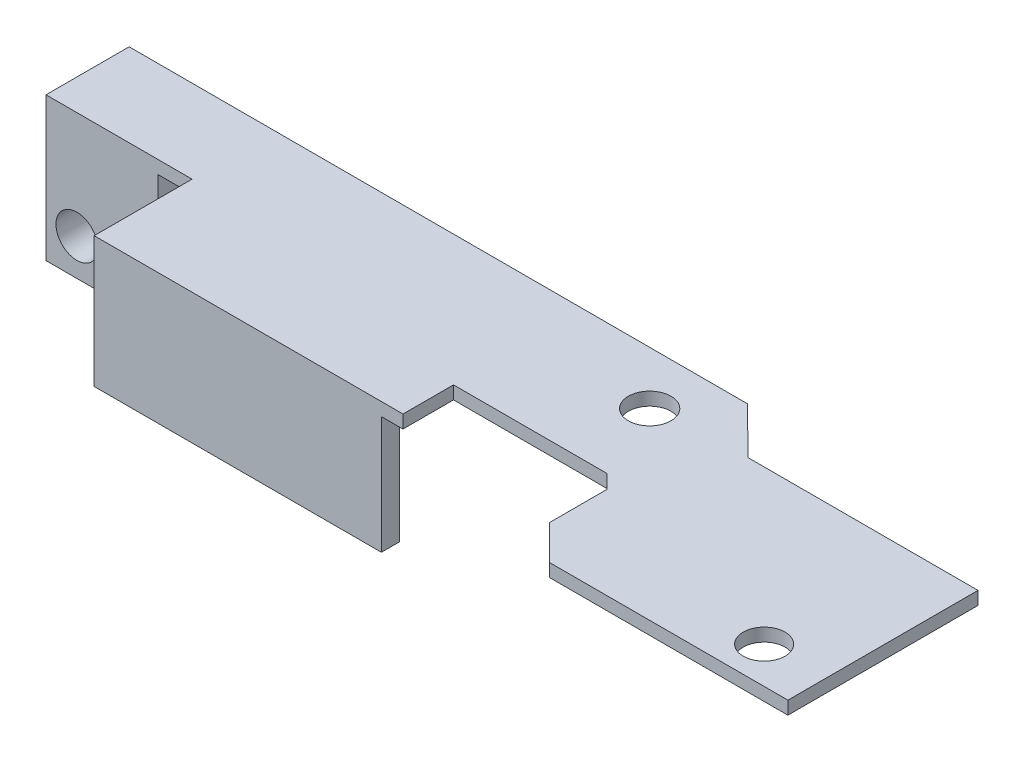
from build123d import *

# Parameters (mm, degrees)
SKETCH_1_R          = 1.632566579
SKETCH_1_R_2        = 1.6
EXTRUDE_1_DEPTH     = 1
SKETCH_2_W          = 21.996438878
SKETCH_2_H          = 1.4
EXTRUDE_2_DEPTH     = 9
SKETCH_3_W          = 9.861847607
SKETCH_3_H          = 7.366382786
EXTRUDE_3_DEPTH     = 10
CUT_EXTRUDE_1_REACH = 9.366
SKETCH_5_R          = 1.6
CUT_EXTRUDE_2_REACH = 13


with BuildPart() as part:
    # 草图1 → 凸台-拉伸1 (new body)
    with BuildSketch(Plane(origin=(0, 0, 0), x_dir=(1, 0, 0), z_dir=(0, 1, 0))):
        Polygon((-59.259088641, 5), (-10.592885375, 5), (-7.033226841, 1.452276921), (10.592885375, 1.452276921), (10.592885375, -5), (10.592885375, -13.105286597), (-7.648958362, -13.105286597), (-10.311746214, -10.442498745), (-10.311746214, -6.049690331), (-11.364057651, -4.997378894), (-11.364090146, -5), (-23.120004307, -5), (-23.120004307, -8.866382786), (-46.772006656, -8.866382786), (-46.772006656, -2.366382786), (-59.259088641, -2.366382786), (-59.259088641, 0), align=None)
        with Locations((-14.039400366, 0.94270398)):
            Circle(SKETCH_1_R, mode=Mode.SUBTRACT)
        with Locations((5.968790226, -10.300345076)):
            Circle(SKETCH_1_R_2, mode=Mode.SUBTRACT)
    extrude(amount=EXTRUDE_1_DEPTH)

    # 草图2 → 凸台-拉伸2 (add)
    with BuildSketch(Plane.XZ):
        with Locations((-35.773787217, 8.166382786)):
            Rectangle(SKETCH_2_W, SKETCH_2_H)
    extrude(amount=EXTRUDE_2_DEPTH)

    # 草图3 → 凸台-拉伸3 (add)
    with BuildSketch(Plane.XZ):
        with Locations((-54.328164838, -1.316808607)):
            Rectangle(SKETCH_3_W, SKETCH_3_H)
    extrude(amount=EXTRUDE_3_DEPTH)

    # 草图5 → 切除-拉伸1 (cut, up to next)
    with BuildSketch(Plane.XY.offset(2.366382786), mode=Mode.PRIVATE) as cut_extrude_1_sk1:
        with Locations((-55.594883285, -7.2)):
            Circle(SKETCH_5_R)
    cut_extrude_1_tool1 = extrude(cut_extrude_1_sk1.sketch, amount=-CUT_EXTRUDE_1_REACH, mode=Mode.PRIVATE) & part.part
    add(cut_extrude_1_tool1.solids().sort_by_distance((-55.594883, -7.2, 2.366383))[0], mode=Mode.SUBTRACT)

    # 草图6 → 切除-拉伸2 (cut, up to next)
    with BuildSketch(Plane(origin=(0, 1, 0), x_dir=(1, 0, 0), z_dir=(0, 1, 0)), mode=Mode.PRIVATE) as cut_extrude_2_sk1:
        Polygon((-59.259088641, 5), (-57.959088641, 5), (-57.959088641, -1.366382786), (-46.772006656, -1.366382786), (-46.772006656, -2.366382786), (-57.959088641, -2.366382786), (-59.259088641, -2.366382786), align=None)
    cut_extrude_2_tool1 = extrude(cut_extrude_2_sk1.sketch, amount=-CUT_EXTRUDE_2_REACH, mode=Mode.PRIVATE) & part.part
    add(cut_extrude_2_tool1.solids().sort_by_distance((-58.609089, 1, -4.85502))[0], mode=Mode.SUBTRACT)


solid = part.part
